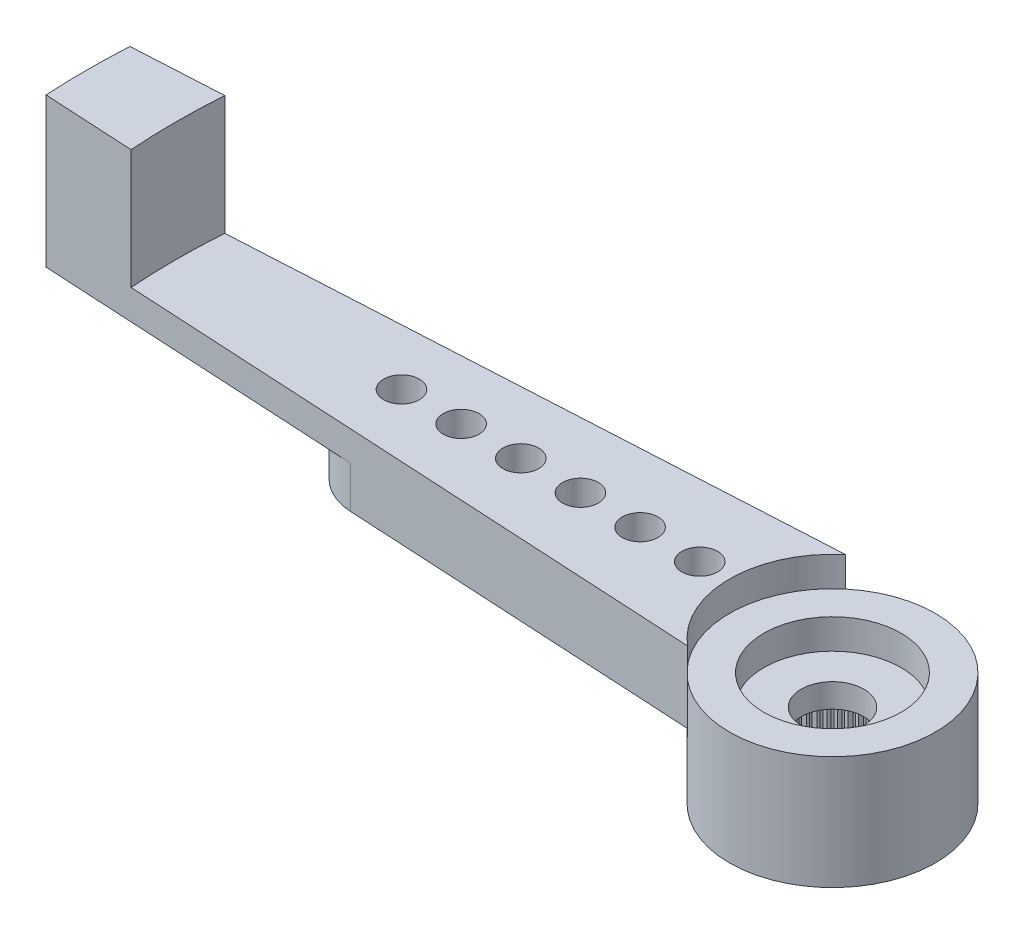
from build123d import *

# Parameters (mm, degrees)
RESSALTO_EXTRUS_O1_DEPTH = 1.4
ESBO_O2_R                = 3.45
RESSALTO_EXTRUS_O2_DEPTH = 2.4
FURO4_D                  = 1.2
PADR_O_LINEAR1_COUNT     = 6
PADR_O_LINEAR1_PITCH     = 2
FURO1_D                  = 4.95
FURO1_DEPTH              = 2
FURO2_D                  = 4.6
FURO2_DEPTH              = 1
FURO3_D                  = 2.1
RESSALTO_EXTRUS_O3_DEPTH = 2
PADR_OCIRCULAR1_COUNT    = 60
BOSS_EXTRUDE2_DEPTH      = 5
SKETCH1_4_R              = 0.6
BOSS_EXTRUDE3_DEPTH      = 1


with BuildPart() as part:
    # Esboço1 → Ressalto-extrusão1 (new body)
    with BuildSketch(Plane(origin=(0, 0, 0), x_dir=(1, 0, 0), z_dir=(0, 1, 0))):
        with BuildLine():
            Line((-14.159121967, 1.99702088), (-2.209072203, 2.65))
            ThreePointArc((-2.209072203, 2.65), (3.45, 0), (-2.209072203, -2.65))
            Line((-2.209072203, -2.65), (-14.159121967, -1.99702088))
            ThreePointArc((-14.159121967, -1.99702088), (-16.05, 0), (-14.159121967, 1.99702088))
        make_face()
    extrude(amount=-RESSALTO_EXTRUS_O1_DEPTH)

    # Esboço2 → Ressalto-extrusão2 (add)
    with BuildSketch(Plane.XZ.offset(1.4)):
        with Locations(Location((0, 0, 0), (0, 0, 90))):
            Circle(ESBO_O2_R)
    extrude(amount=RESSALTO_EXTRUS_O2_DEPTH)

    # Furo4 (through all)
    with Locations(Plane(origin=(0, 0, 0), x_dir=(1, 0, 0), z_dir=(0, 1, 0))):
        with Locations((-14.45, 0)):
            furo4 = Hole(FURO4_D / 2)

    # Padrão linear1: Furo4 ×6
    with Locations(*[(i * PADR_O_LINEAR1_PITCH, 0, 0) for i in range(1, PADR_O_LINEAR1_COUNT)]):
        add(furo4, mode=Mode.SUBTRACT)

    # Furo1
    with Locations(Plane(origin=(0, -3.8, 0), x_dir=(-1, 0, 0), z_dir=(0, -1, 0))):
        with Locations((0, 0)):
            Hole(FURO1_D / 2, depth=FURO1_DEPTH)

    # Furo2
    with Locations(Plane(origin=(0, 0, 0), x_dir=(1, 0, 0), z_dir=(0, 1, 0))):
        with Locations((0, 0)):
            Hole(FURO2_D / 2, depth=FURO2_DEPTH)

    # Furo3 (through all)
    with Locations(Plane(origin=(0, 0, 0), x_dir=(1, 0, 0), z_dir=(0, 1, 0))):
        with Locations((0, 0)):
            Hole(FURO3_D / 2)

    # Esboço11 → Ressalto-extrusão3 (add)
    with BuildSketch(Plane.XZ.offset(3.8)):
        with BuildLine():
            Line((-0.098056786, 2.473056786), (0, 2.375))
            Line((0, 2.375), (0.098056786, 2.473056786))
            ThreePointArc((0.098056786, 2.473056786), (0, 2.475), (-0.098056786, 2.473056786))
        make_face()
    ressalto_extrus_o3 = extrude(amount=-RESSALTO_EXTRUS_O3_DEPTH)

    # PadrãoCircular1: Ressalto-extrusão3 ×60 about axis
    padr_ocircular1_axis = Axis((0, 0, 0), (0, 1, 0))
    for i in range(1, PADR_OCIRCULAR1_COUNT):
        add(ressalto_extrus_o3.rotate(padr_ocircular1_axis, i * 360 / PADR_OCIRCULAR1_COUNT))



with BuildPart() as body_2:
    # Sketch1 → Boss-Extrude2 (new body)
    with BuildSketch(Plane(origin=(0, 0, 0), x_dir=(1, 0, 0), z_dir=(0, 1, 0))):
        with BuildLine():
            ThreePointArc((-21.94379006, -1.571648115), (-22, 0), (-21.94379006, 1.571648115))
            Line((-21.94379006, 1.571648115), (-24.960386094, 1.406814138))
            ThreePointArc((-24.960386094, 1.406814138), (-25, 0), (-24.960386094, -1.406814138))
            Line((-24.960386094, -1.406814138), (-21.94379006, -1.571648115))
        make_face()
    extrude(amount=BOSS_EXTRUDE2_DEPTH)


with BuildPart() as part_1:
    add(part.part)

    add(body_2.part)  # Boss-Extrude3 merges body 2
    # Sketch1_4 → Boss-Extrude3 (add)
    with BuildSketch(Plane(origin=(0, 0, 0), x_dir=(1, 0, 0), z_dir=(0, 1, 0))):
        with BuildLine():
            ThreePointArc((-14.159121967, -1.99702088), (-16.05, 0), (-14.159121967, 1.99702088))
            Line((-14.159121967, 1.99702088), (-21.94379006, 1.571648115))
            ThreePointArc((-21.94379006, 1.571648115), (-22, 0), (-21.94379006, -1.571648115))
            Line((-21.94379006, -1.571648115), (-14.159121967, -1.99702088))
        make_face()
        with BuildLine():
            ThreePointArc((-2.209072203, 2.65), (-3.45, 0), (-2.209072203, -2.65))
            Line((-2.209072203, -2.65), (-14.159121967, -1.99702088))
            ThreePointArc((-14.159121967, -1.99702088), (-16.05, 0), (-14.159121967, 1.99702088))
            Line((-14.159121967, 1.99702088), (-2.209072203, 2.65))
        make_face()
        with Locations(Location((-12.45, 0, 0), (0, 0, 270))):
            Circle(SKETCH1_4_R, mode=Mode.SUBTRACT)
        with Locations(Location((-8.45, 0, 0), (0, 0, 270))):
            Circle(SKETCH1_4_R, mode=Mode.SUBTRACT)
        with Locations(Location((-4.45, 0, 0), (0, 0, 270))):
            Circle(SKETCH1_4_R, mode=Mode.SUBTRACT)
        with Locations(Location((-6.45, 0, 0), (0, 0, 270))):
            Circle(SKETCH1_4_R, mode=Mode.SUBTRACT)
        with Locations(Location((-10.45, 0, 0), (0, 0, 270))):
            Circle(SKETCH1_4_R, mode=Mode.SUBTRACT)
        with Locations(Location((-14.45, 0, 0), (0, 0, 270))):
            Circle(SKETCH1_4_R, mode=Mode.SUBTRACT)
    extrude(amount=BOSS_EXTRUDE3_DEPTH)


solid = part_1.part
